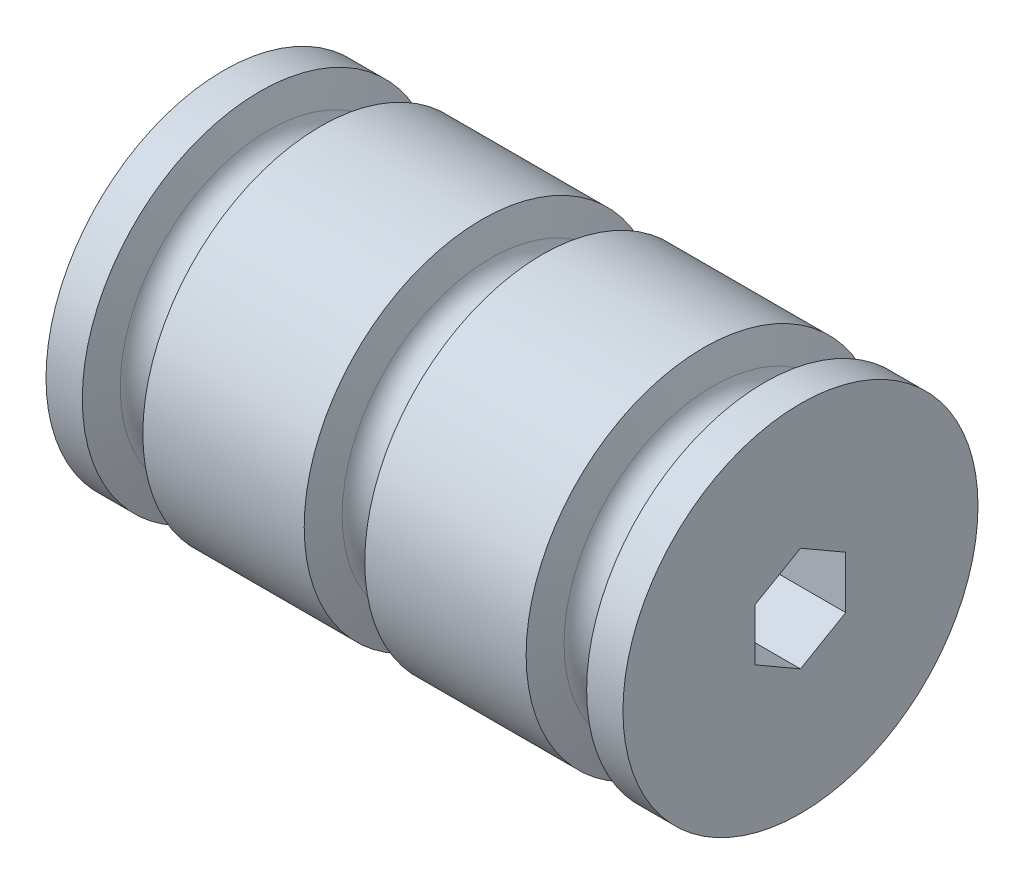
from build123d import *

# Parameters (mm, degrees)
SKETCH1_W          = 82.55
SKETCH1_H          = 25.4
CUT_EXTRUDE1_DEPTH = 83.55


with BuildPart() as part:
    # Sketch1 → Revolve1 (revolve)
    with BuildSketch(Plane.XY):
        with Locations((41.275, 12.7)):
            Rectangle(SKETCH1_W, SKETCH1_H)
    revolve(axis=Axis((0, 0, 0), (-1, 0, 0)))

    # Sketch2 → Cut-Revolve1 (revolve, cut)
    with BuildSketch(Plane.XY):
        with BuildLine():
            Line((5.194846373, 25.4), (6.496948681, 21.270259087))
            ThreePointArc((6.496948681, 21.270259087), (9.525, 19.05), (12.553051319, 21.270259087))
            Line((12.553051319, 21.270259087), (13.855153627, 25.4))
            Line((13.855153627, 25.4), (5.194846373, 25.4))
        make_face()
        with BuildLine():
            Line((36.944846373, 25.4), (38.246948681, 21.270259087))
            ThreePointArc((38.246948681, 21.270259087), (41.275, 19.05), (44.303051319, 21.270259087))
            Line((44.303051319, 21.270259087), (45.605153627, 25.4))
            Line((45.605153627, 25.4), (36.944846373, 25.4))
        make_face()
        with BuildLine():
            Line((68.694846373, 25.4), (69.996948681, 21.270259087))
            ThreePointArc((69.996948681, 21.270259087), (73.025, 19.05), (76.053051319, 21.270259087))
            Line((76.053051319, 21.270259087), (77.355153627, 25.4))
            Line((77.355153627, 25.4), (68.694846373, 25.4))
        make_face()
    revolve(axis=Axis((0, 0, 0), (-1, 0, 0)), mode=Mode.SUBTRACT)

    # Sketch3 → Cut-Extrude1 (cut, through all)
    with BuildSketch(Plane.ZY):
        Polygon((0, 7.478995387), (-6.477, 3.739497694), (-6.477, -3.739497694), (0, -7.478995387), (6.477, -3.739497694), (6.477, 3.739497694), align=None)
    extrude(amount=-CUT_EXTRUDE1_DEPTH, mode=Mode.SUBTRACT)


solid = part.part
